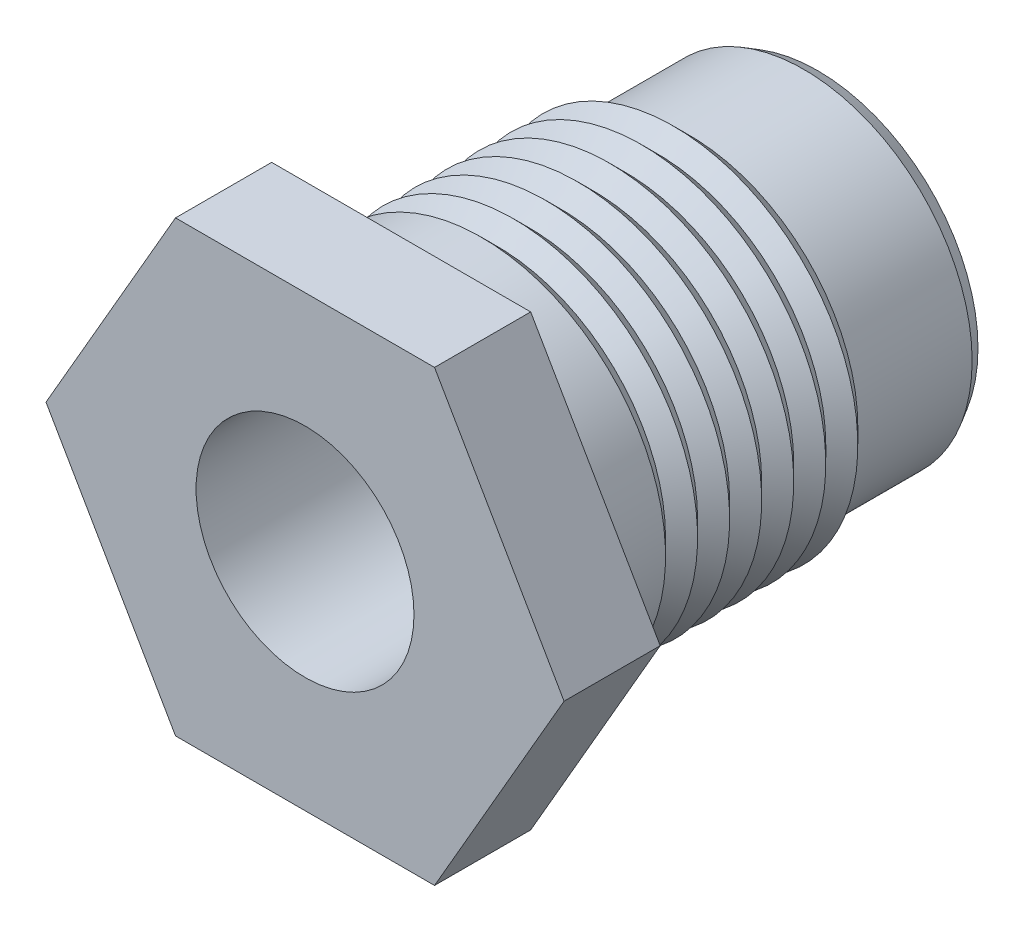
from build123d import *

# Parameters (mm, degrees)
SKETCH1_R       = 3.4
EXTRUDE1_DEPTH  = 16
LPATTERN2_COUNT = 6
LPATTERN2_PITCH = 1


with BuildPart() as part:
    # Sketch1 → Extrude1 (new body)
    with BuildSketch(Plane.XY):
        Polygon((8.082903769, 0), (4.041451884, 7), (-4.041451884, 7), (-8.082903769, 0), (-4.041451884, -7), (4.041451884, -7), align=None)
        Circle(SKETCH1_R, mode=Mode.SUBTRACT)
    extrude(amount=EXTRUDE1_DEPTH)

    # Sketch2 → Cut-Revolve1 (revolve, cut)
    with BuildSketch(Plane(origin=(0, 0, 0), x_dir=(1, 0, 0), z_dir=(0, 1, 0))):
        with BuildLine():
            Line((5.75, -4.5), (5.75, -12.6))
            ThreePointArc((5.75, -12.6), (5.867157288, -12.882842712), (6.15, -13))
            Line((6.15, -13), (8.082903769, -13))
            Line((8.082903769, -13), (8.082903769, 0))
            Line((8.082903769, 0), (5, 0))
            Line((5, 0), (5.25, -0.433012702))
            Line((5.25, -0.433012702), (5.25, -4))
            Line((5.25, -4), (5.75, -4.5))
        make_face()
    revolve(axis=Axis((0, 0, 0), (0, 0, 1)), mode=Mode.SUBTRACT)

    # Sketch4 → Cut-Revolve2 (revolve, cut)
    with BuildSketch(Plane(origin=(0, 0, 0), x_dir=(1, 0, 0), z_dir=(0, 1, 0))):
        Polygon((5.75, -4.5), (5.75, -5.5), (5.25, -5), align=None)
    cut_revolve2 = revolve(axis=Axis((0, 0, 0), (0, 0, 1)), mode=Mode.SUBTRACT)

    # LPattern2: Cut-Revolve2 ×6
    with Locations(*[(0, 0, i * LPATTERN2_PITCH) for i in range(1, LPATTERN2_COUNT)]):
        add(cut_revolve2, mode=Mode.SUBTRACT)


solid = part.part
